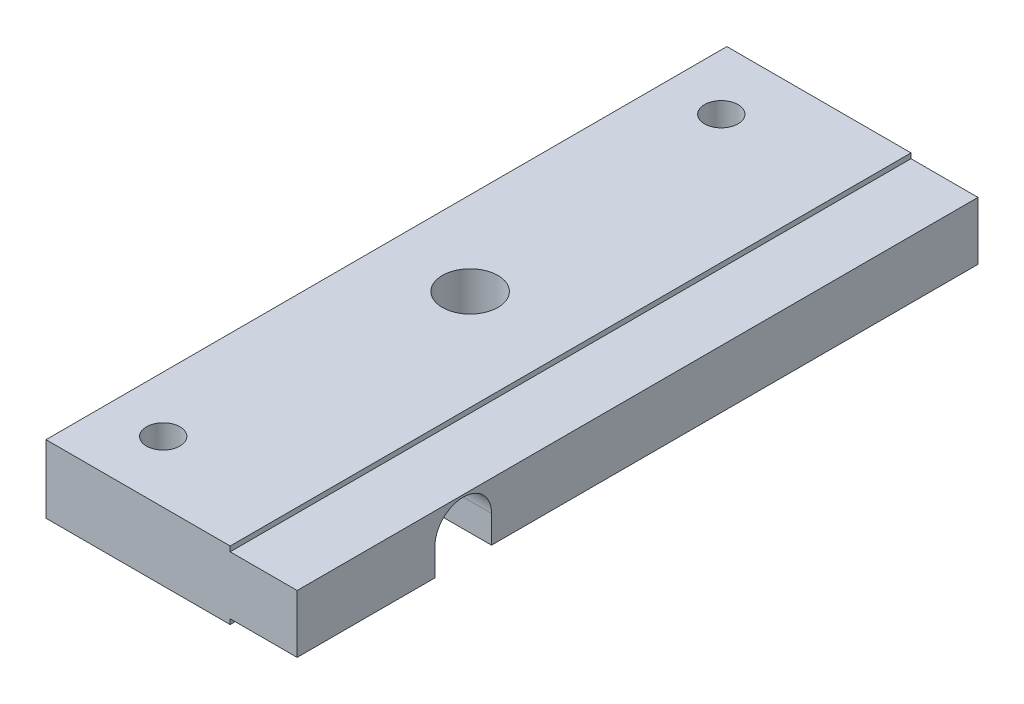
from build123d import *

# Parameters (mm, degrees)
SKETCH1_W           = 61
SKETCH1_H           = 6.1
BOSS_EXTRUDE1_DEPTH = 22.5
SKETCH2_OUTSIDE_W   = 76.06
SKETCH2_OUTSIDE_H   = 21.16
SKETCH2_OUTSIDE_W_2 = 61
SKETCH2_OUTSIDE_H_2 = 5.1952
CUT_EXTRUDE1_DEPTH  = 6
CUT_EXTRUDE3_DEPTH  = 23.5
SKETCH6_R           = 2.4892
CUT_EXTRUDE4_DEPTH  = 7.1
SKETCH7_R           = 1.5
CUT_EXTRUDE5_DEPTH  = 7.1


with BuildPart() as part:
    # Sketch1 → Boss-Extrude1 (new body)
    with BuildSketch(Plane(origin=(0, 0, 0), x_dir=(0, 0, -1), z_dir=(1, 0, 0))):
        with Locations((30.5, 0)):
            Rectangle(SKETCH1_W, SKETCH1_H)
    extrude(amount=BOSS_EXTRUDE1_DEPTH)

    # Sketch2 outside → Cut-Extrude1 (cut)
    with BuildSketch(Plane(origin=(22.5, 0, 0), x_dir=(0, 0, -1), z_dir=(1, 0, 0))):
        with Locations((30.5, 0)):
            Rectangle(SKETCH2_OUTSIDE_W, SKETCH2_OUTSIDE_H)
        with Locations((30.5, 0)):
            Rectangle(SKETCH2_OUTSIDE_W_2, SKETCH2_OUTSIDE_H_2, mode=Mode.SUBTRACT)
    extrude(amount=-CUT_EXTRUDE1_DEPTH, mode=Mode.SUBTRACT)

    # Sketch5 → Cut-Extrude3 (cut, through all)
    with BuildSketch(Plane.ZY):
        with BuildLine():
            Line((-12.3486, -0.1278), (-12.3486, -3.05))
            Line((-12.3486, -3.05), (-17.4134, -3.05))
            Line((-17.4134, -3.05), (-17.4134, -0.1278))
            ThreePointArc((-17.4134, -0.1278), (-14.881, 2.4046), (-12.3486, -0.1278))
        make_face()
    extrude(amount=-CUT_EXTRUDE3_DEPTH, mode=Mode.SUBTRACT)

    # Sketch6 → Cut-Extrude4 (cut, through all)
    with BuildSketch(Plane(origin=(0, 3.05, 0), x_dir=(1, 0, 0), z_dir=(0, 1, 0))):
        with Locations(Location((7.5, 30.5, 0), (0, 0, 270))):  # turned: the seam where the file's is
            Circle(SKETCH6_R)
    extrude(amount=-CUT_EXTRUDE4_DEPTH, mode=Mode.SUBTRACT)

    # Sketch7 → Cut-Extrude5 (cut, through all)
    with BuildSketch(Plane(origin=(0, 3.05, 0), x_dir=(1, 0, 0), z_dir=(0, 1, 0))):
        with Locations(Location((5, 55.5, 0), (0, 0, 270))):  # turned: the seam where the file's is
            Circle(SKETCH7_R)
        with Locations(Location((5, 5.5, 0), (0, 0, 270))):  # turned: the seam where the file's is
            Circle(SKETCH7_R)
    extrude(amount=-CUT_EXTRUDE5_DEPTH, mode=Mode.SUBTRACT)


solid = part.part
